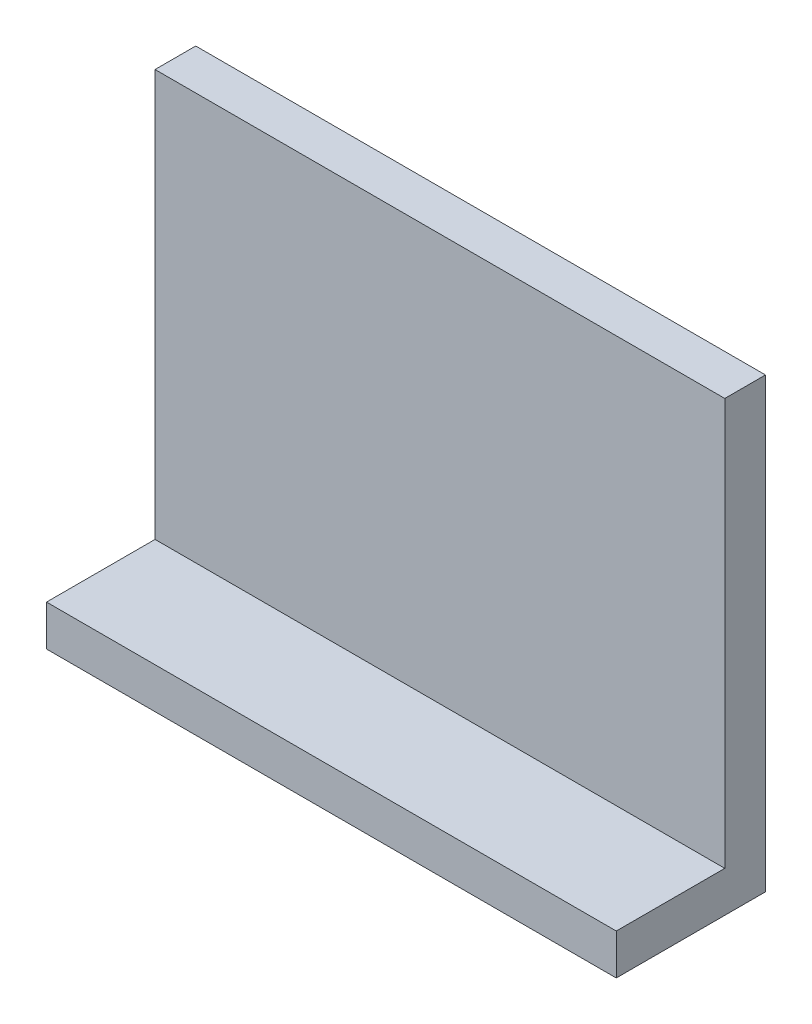
from build123d import *

# Parameters (mm, degrees)
SKETCH1_W           = 42
SKETCH1_H           = 33
BOSS_EXTRUDE1_DEPTH = 3
SKETCH2_W           = 42
SKETCH2_H           = 3
BOSS_EXTRUDE2_DEPTH = 8


with BuildPart() as part:
    # Sketch1 → Boss-Extrude1 (new body)
    with BuildSketch(Plane.XY):
        with Locations((21, 16.5)):
            Rectangle(SKETCH1_W, SKETCH1_H)
    extrude(amount=BOSS_EXTRUDE1_DEPTH)

    # Sketch2 → Boss-Extrude2 (add)
    with BuildSketch(Plane.XY.offset(3)):
        with Locations((21, 1.5)):
            Rectangle(SKETCH2_W, SKETCH2_H)
    extrude(amount=BOSS_EXTRUDE2_DEPTH)


solid = part.part
